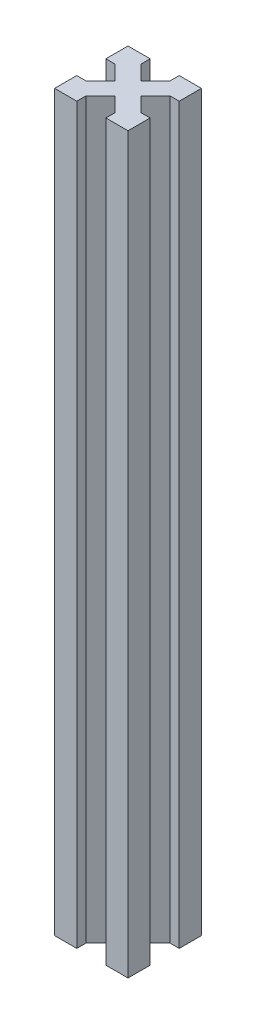
from build123d import *

# Parameters (mm, degrees)
BOSS_EXTRU_1_DEPTH = 200


with BuildPart() as part:
    # Esquisse1 → Boss.-Extru.1 (new body)
    with BuildSketch(Plane(origin=(0, 0, 0), x_dir=(1, 0, 0), z_dir=(0, 1, 0))):
        Polygon((-3.535533906, 0), (-6.035533906, 2.5), (-6.035533906, 0), align=None)
        Polygon((0, 3.535533906), (-2.5, 6.035533906), (-2.5, 2.5), (-6.035533906, 2.5), (-3.535533906, 0), (0, 0), align=None)
        Polygon((0, 6.035533906), (-2.5, 6.035533906), (0, 3.535533906), align=None)
        Polygon((-2.5, 2.5), (-2.5, 6.035533906), (-6.464466094, 10), (-10, 6.464466094), (-6.035533906, 2.5), align=None)
        Polygon((-13.964466094, 0), (-13.964466094, 2.5), (-16.464466094, 0), align=None)
        Polygon((-17.5, 2.5), (-17.5, 6.035533906), (-20, 3.535533906), (-20, 0), (-16.464466094, 0), (-13.964466094, 2.5), align=None)
        Polygon((-20, 3.535533906), (-17.5, 6.035533906), (-20, 6.035533906), align=None)
        Polygon((-10, 6.464466094), (-13.535533906, 10), (-17.5, 6.035533906), (-17.5, 2.5), (-13.964466094, 2.5), align=None)
        Polygon((-6.464466094, 10), (-10, 13.535533906), (-13.535533906, 10), (-10, 6.464466094), align=None)
        Polygon((-2.5, 13.964466094), (-2.5, 17.5), (-6.035533906, 17.5), (-10, 13.535533906), (-6.464466094, 10), align=None)
        Polygon((-6.035533906, 17.5), (-2.5, 17.5), (-2.5, 13.964466094), (0, 16.464466094), (0, 20), (-3.535533906, 20), align=None)
        Polygon((0, 16.464466094), (-2.5, 13.964466094), (0, 13.964466094), align=None)
        Polygon((-6.035533906, 20), (-6.035533906, 17.5), (-3.535533906, 20), align=None)
        Polygon((-16.464466094, 20), (-13.964466094, 17.5), (-13.964466094, 20), align=None)
        Polygon((-17.5, 17.5), (-13.964466094, 17.5), (-16.464466094, 20), (-20, 20), (-20, 16.464466094), (-17.5, 13.964466094), align=None)
        Polygon((-20, 13.964466094), (-17.5, 13.964466094), (-20, 16.464466094), align=None)
        Polygon((-10, 13.535533906), (-13.964466094, 17.5), (-17.5, 17.5), (-17.5, 13.964466094), (-13.535533906, 10), align=None)
    extrude(amount=BOSS_EXTRU_1_DEPTH)


solid = part.part
